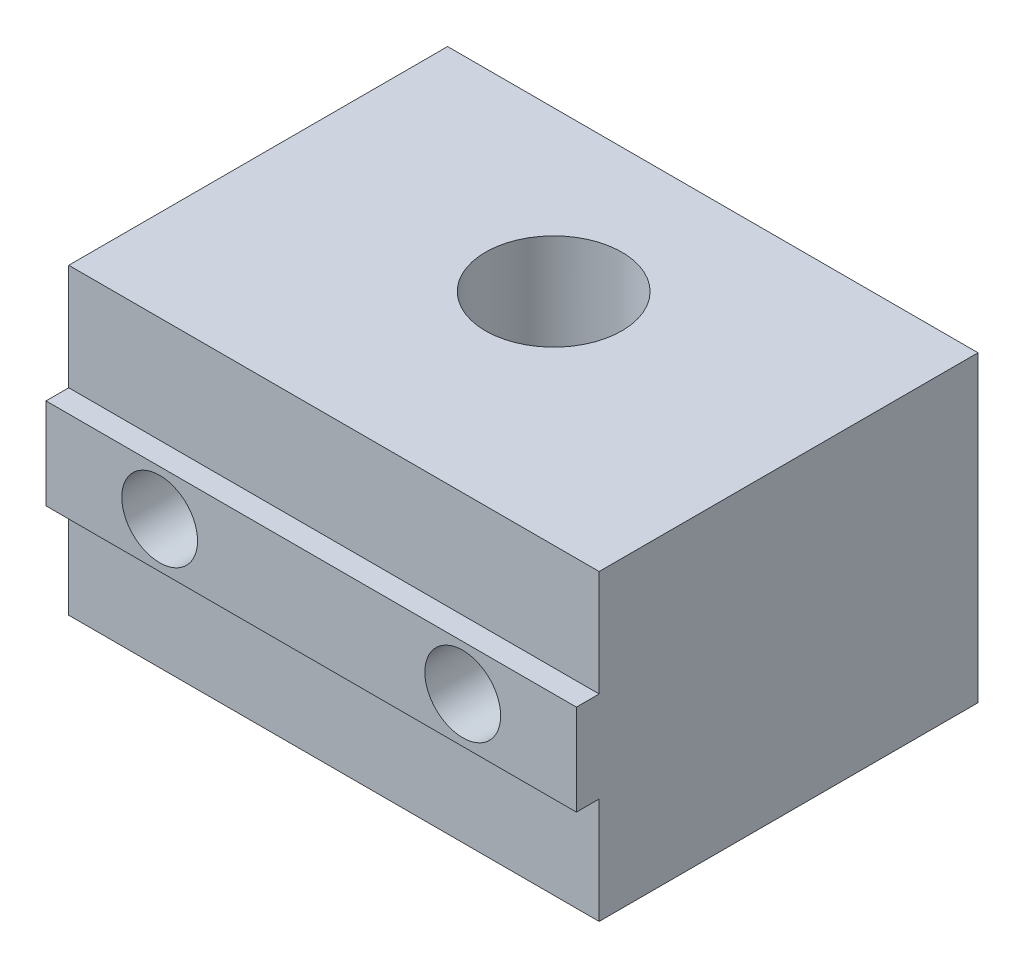
from build123d import *

# Parameters (mm, degrees)
SKETCH1_W           = 35
SKETCH1_H           = 25
BOSS_EXTRUDE1_DEPTH = 20
SKETCH5_W           = 1.5
SKETCH5_H           = 6
BOSS_EXTRUDE2_DEPTH = 35
SKETCH2_R           = 4.5
CUT_EXTRUDE1_DEPTH  = 21
SKETCH3_R           = 2.5
CUT_EXTRUDE4_DEPTH  = 27.5
SKETCH4_R           = 5
SKETCH4_R_2         = 2.5
CUT_EXTRUDE5_DEPTH  = 5


with BuildPart() as part:
    # Sketch1 → Boss-Extrude1 (new body)
    with BuildSketch(Plane(origin=(0, 0, 0), x_dir=(1, 0, 0), z_dir=(0, 1, 0))):
        with Locations((17.5, 12.5)):
            Rectangle(SKETCH1_W, SKETCH1_H)
    extrude(amount=BOSS_EXTRUDE1_DEPTH)

    # Sketch5 → Boss-Extrude2 (add, through all)
    with BuildSketch(Plane(origin=(35, 0, 0), x_dir=(0, 0, -1), z_dir=(1, 0, 0))):
        with Locations((-0.75, 10)):
            Rectangle(SKETCH5_W, SKETCH5_H)
    extrude(amount=-BOSS_EXTRUDE2_DEPTH)

    # Sketch2 → Cut-Extrude1 (cut, through all)
    with BuildSketch(Plane(origin=(0, 20, 0), x_dir=(1, 0, 0), z_dir=(0, 1, 0))):
        with Locations((17.5, 14.5)):
            Circle(SKETCH2_R)
    extrude(amount=-CUT_EXTRUDE1_DEPTH, mode=Mode.SUBTRACT)

    # Sketch3 → Cut-Extrude4 (cut, through all)
    with BuildSketch(Plane(origin=(0, 0, -25), x_dir=(-1, 0, 0), z_dir=(0, 0, -1))):
        with Locations((-7.5, 10)):
            Circle(SKETCH3_R)
        with Locations((-27.5, 10)):
            Circle(SKETCH3_R)
    extrude(amount=-CUT_EXTRUDE4_DEPTH, mode=Mode.SUBTRACT)

    # Sketch4 → Cut-Extrude5 (cut)
    with BuildSketch(Plane(origin=(0, 0, -25), x_dir=(-1, 0, 0), z_dir=(0, 0, -1))):
        with Locations((-7.5, 10)):
            Circle(SKETCH4_R)
        with Locations((-7.5, 10)):
            Circle(SKETCH4_R_2, mode=Mode.SUBTRACT)
        with Locations((-27.5, 10)):
            Circle(SKETCH4_R)
        with Locations((-27.5, 10)):
            Circle(SKETCH4_R_2, mode=Mode.SUBTRACT)
    extrude(amount=-CUT_EXTRUDE5_DEPTH, mode=Mode.SUBTRACT)


solid = part.part
